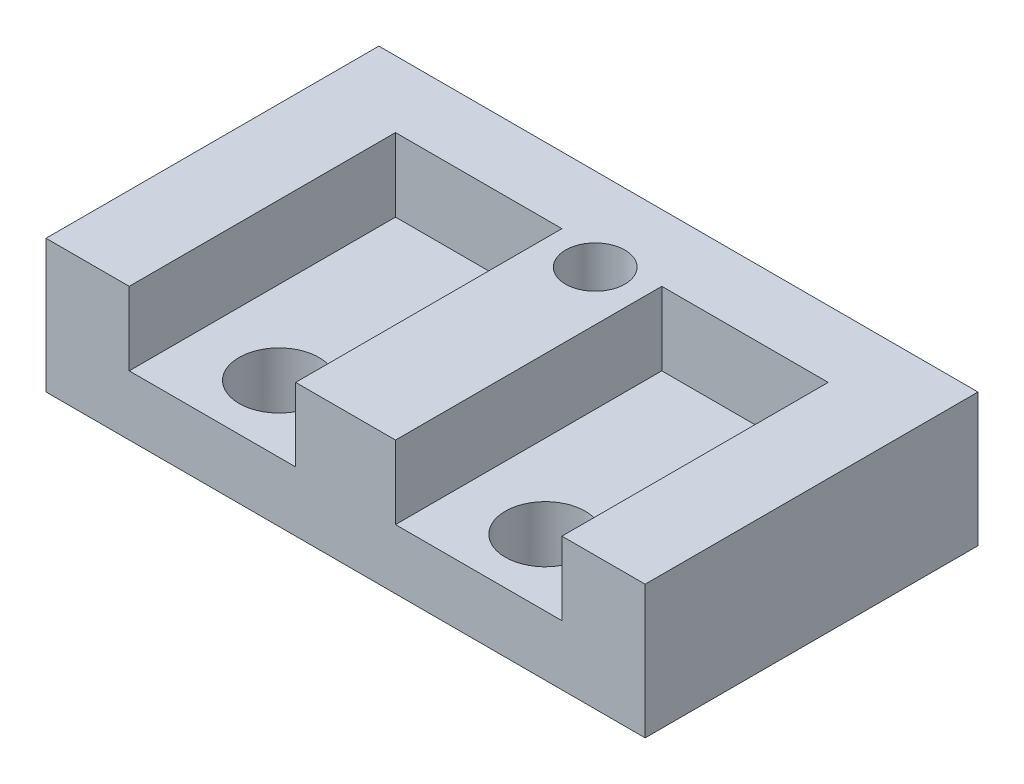
from build123d import *

# Parameters (mm, degrees)
SKETCH1_W                      = 22.86
SKETCH1_H                      = 12.7
BOSS_EXTRUDE1_DEPTH            = 5.08
F_4_40_TAPPED_HOLE1_D          = 2.2606
F_4_40_TAPPED_HOLE1_DEPTH      = 7.5946
F_4_40_TAPPED_HOLE1_TIP        = 0.679152758
SKETCH5_W                      = 6.35
SKETCH5_H                      = 10.16
CUT_EXTRUDE1_DEPTH             = 2.794
F_31_0_12_DIAMETER_HOLE1_D     = 3.048
F_31_0_12_DIAMETER_HOLE1_DEPTH = 7.5946
F_31_0_12_DIAMETER_HOLE1_TIP   = 0.915711583


with BuildPart() as part:
    # Sketch1 → Boss-Extrude1 (new body)
    with BuildSketch(Plane(origin=(0, 0, 0), x_dir=(1, 0, 0), z_dir=(0, 1, 0))):
        Rectangle(SKETCH1_W, SKETCH1_H)
    extrude(amount=BOSS_EXTRUDE1_DEPTH)

    # #4-40 Tapped Hole1
    with Locations(Plane(origin=(0, 5.08, 0), x_dir=(1, 0, 0), z_dir=(0, 1, 0))):
        with Locations((0, 3.175)):
            Hole(F_4_40_TAPPED_HOLE1_D / 2, depth=F_4_40_TAPPED_HOLE1_DEPTH)
            with Locations((0, 0, -(F_4_40_TAPPED_HOLE1_DEPTH + F_4_40_TAPPED_HOLE1_TIP / 2))):  # 118° drill point
                Cone(0, F_4_40_TAPPED_HOLE1_D / 2, F_4_40_TAPPED_HOLE1_TIP, mode=Mode.SUBTRACT)

    # Sketch5 → Cut-Extrude1 (cut)
    with BuildSketch(Plane(origin=(0, 5.08, 0), x_dir=(1, 0, 0), z_dir=(0, 1, 0))):
        with Locations((-5.08, -1.27)):
            Rectangle(SKETCH5_W, SKETCH5_H)
        with Locations((5.08, -1.27)):
            Rectangle(SKETCH5_W, SKETCH5_H)
    extrude(amount=-CUT_EXTRUDE1_DEPTH, mode=Mode.SUBTRACT)

    # #31 (0.12) Diameter Hole1
    with Locations(Plane(origin=(0, 2.286, 0), x_dir=(1, 0, 0), z_dir=(0, 1, 0))):
        with Locations((-5.08, -3.81), (5.08, -3.81)):
            Hole(F_31_0_12_DIAMETER_HOLE1_D / 2, depth=F_31_0_12_DIAMETER_HOLE1_DEPTH)
            with Locations((0, 0, -(F_31_0_12_DIAMETER_HOLE1_DEPTH + F_31_0_12_DIAMETER_HOLE1_TIP / 2))):  # 118° drill point
                Cone(0, F_31_0_12_DIAMETER_HOLE1_D / 2, F_31_0_12_DIAMETER_HOLE1_TIP, mode=Mode.SUBTRACT)


solid = part.part
